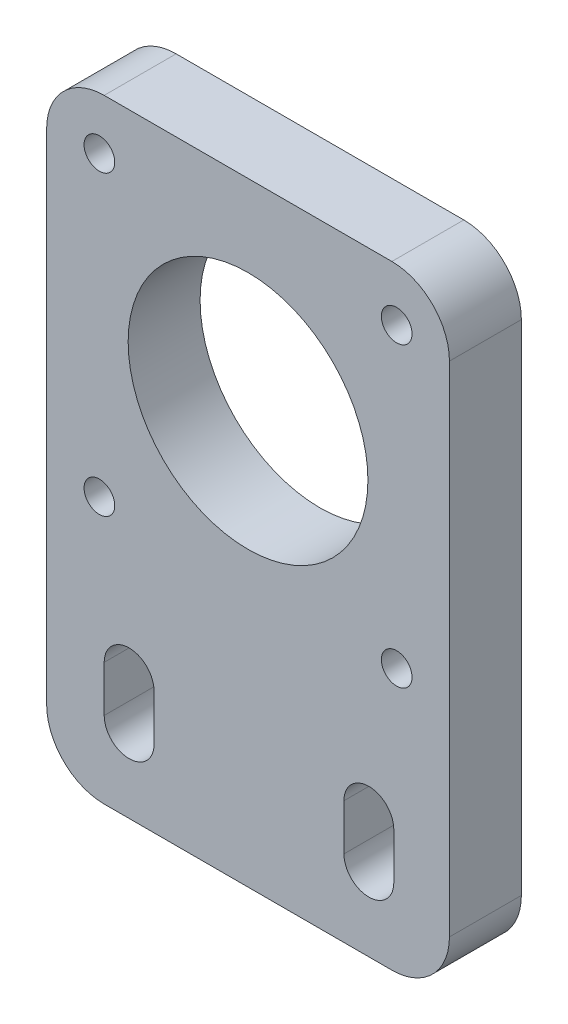
from build123d import *

# Parameters (mm, degrees)
SKETCH_1_R      = 12.5
SKETCH_1_R_2    = 1.6
EXTRUDE_1_DEPTH = 7.5


with BuildPart() as part:
    # 草图1 → 凸台-拉伸1 (new body)
    with BuildSketch(Plane.XY):
        with BuildLine():
            Line((-11.594594595, 38.594594595), (18.405405405, 38.594594595))
            ThreePointArc((18.405405405, 38.594594595), (22.648046093, 36.837235282), (24.405405405, 32.594594595))
            Line((24.405405405, 32.594594595), (24.405405405, -19.405405405))
            ThreePointArc((24.405405405, -19.405405405), (22.648046093, -23.648046093), (18.405405405, -25.405405405))
            Line((18.405405405, -25.405405405), (-11.594594595, -25.405405405))
            ThreePointArc((-11.594594595, -25.405405405), (-15.837235282, -23.648046093), (-17.594594595, -19.405405405))
            Line((-17.594594595, -19.405405405), (-17.594594595, 32.594594595))
            ThreePointArc((-17.594594595, 32.594594595), (-15.837235282, 36.837235282), (-11.594594595, 38.594594595))
        make_face()
        with Locations((3.405405405, 17.594594595)):
            Circle(SKETCH_1_R, mode=Mode.SUBTRACT)
        with Locations((-12.094594595, 33.094594595)):
            Circle(SKETCH_1_R_2, mode=Mode.SUBTRACT)
        with Locations((18.905405405, 33.094594595)):
            Circle(SKETCH_1_R_2, mode=Mode.SUBTRACT)
        with Locations((18.905405405, 2.094594595)):
            Circle(SKETCH_1_R_2, mode=Mode.SUBTRACT)
        with Locations((-12.094594595, 2.094594595)):
            Circle(SKETCH_1_R_2, mode=Mode.SUBTRACT)
        with BuildLine():
            Line((13.405405405, -12.605405405), (13.405405405, -17.40540541))
            ThreePointArc((13.405405405, -17.40540541), (16.005405405, -20.00540541), (18.605405405, -17.40540541))
            Line((18.605405405, -17.40540541), (18.605405405, -12.605405405))
            ThreePointArc((18.605405405, -12.605405405), (16.005405405, -10.005405405), (13.405405405, -12.605405405))
        make_face(mode=Mode.SUBTRACT)
        with BuildLine():
            Line((-11.594594595, -12.605405405), (-11.594594595, -17.40540541))
            ThreePointArc((-11.594594595, -17.40540541), (-8.994594595, -20.00540541), (-6.394594595, -17.40540541))
            Line((-6.394594595, -17.40540541), (-6.394594595, -12.605405405))
            ThreePointArc((-6.394594595, -12.605405405), (-8.994594595, -10.005405405), (-11.594594595, -12.605405405))
        make_face(mode=Mode.SUBTRACT)
    extrude(amount=-EXTRUDE_1_DEPTH)


solid = part.part
